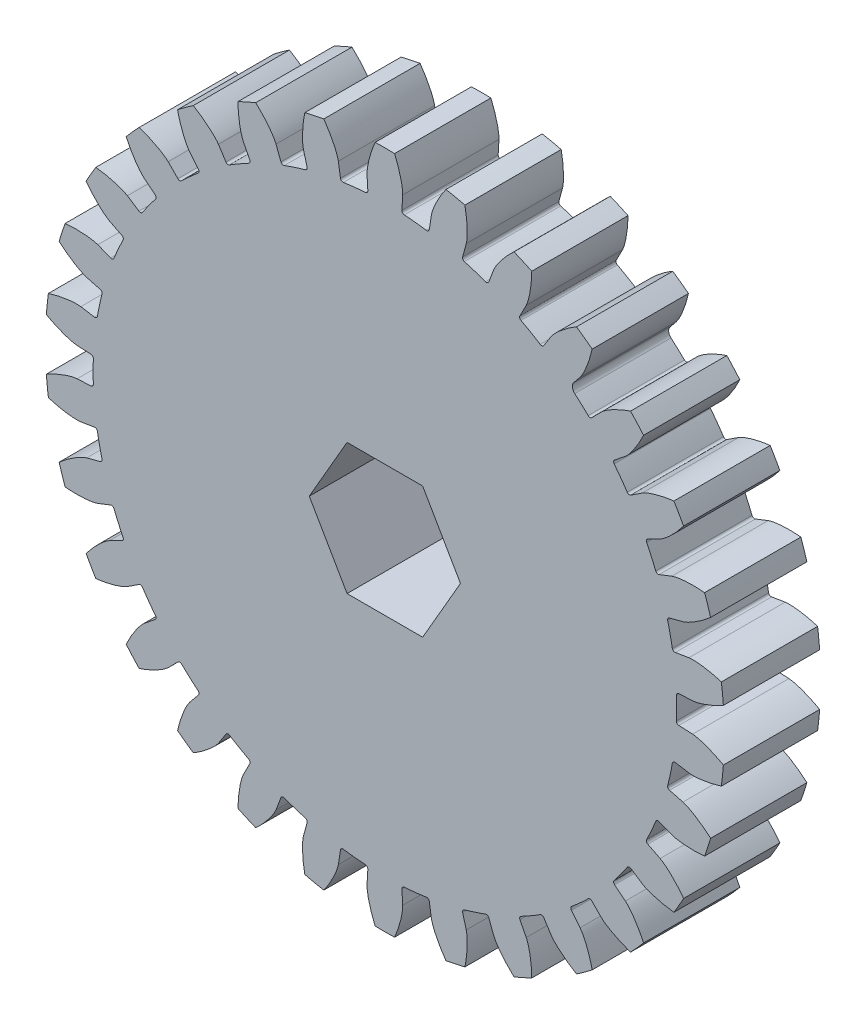
from build123d import *

# Parameters (mm, degrees)
BOSS_EXTRUDE2_DEPTH = 9.525
CUT_EXTRUDE1_DEPTH  = 10.525
CIRPATTERN1_COUNT   = 30
FILLET1_R           = 0.656191159
FILLET2_R           = 0.254
FILLET3_R           = 0.254
SKETCH2_R           = 3.175
CUT_EXTRUDE2_DEPTH  = 2.54
SKETCH3_R           = 3.175
BOSS_EXTRUDE3_DEPTH = 9.525
CUT_EXTRUDE3_DEPTH  = 10.5250001


with BuildPart() as part:
    # Sketch1 → Boss-Extrude2 (new body)
    with BuildSketch(Plane.XY):
        with BuildLine():
            add(Edge.make_bspline(
                [(30.45124914, 1.426618654), (30.456061858, 1.426891336), (30.469553395, 1.427802063), (30.49503231, 1.430100136), (30.536568161, 1.43466882), (30.589432197, 1.441694058), (30.657689376, 1.452157439), (30.738003128, 1.466263239), (30.826163492, 1.483630667), (30.921963231, 1.504540364), (31.017431444, 1.527183187), (31.112562952, 1.551430634), (31.207232939, 1.57708267), (31.321790383, 1.609926897), (31.458987695, 1.65177289), (31.619093687, 1.704276291), (31.800365602, 1.768064008), (31.984767175, 1.837616216), (32.165929064, 1.909788843), (32.348624865, 1.987009098), (32.525148346, 2.06476986), (32.708139717, 2.149952723), (32.876864677, 2.230823601), (33.065486053, 2.326321095), (33.217584866, 2.404815536), (33.374352642, 2.489986603), (33.450600871, 2.532043297), (33.489546581, 2.553791229)],
                knots=[0, 0, 0, 0, 0, 0.005376749, 0.015083688, 0.02853182, 0.04661014, 0.064854849, 0.092110526, 0.119476176, 0.146842496, 0.174208854, 0.201574956, 0.228941013, 0.256307345, 0.307035032, 0.361767352, 0.416499661, 0.471231937, 0.525964282, 0.580696616, 0.635428982, 0.690161387, 0.744893688, 0.799626082, 0.854358407, 0.909090914, 0.909090914, 0.909090914, 0.909090914, 0.909090914], degree=4))
            Line((30.45124914, 1.426618654), (28.832012682, 1.350758615))
            ThreePointArc((28.832012682, 1.350758615), (28.863636364, 0), (28.832012682, -1.350758615))
            Line((28.832012682, -1.350758615), (30.45124914, -1.426618654))
            add(Edge.make_bspline(
                [(30.45124914, -1.426618654), (30.456061858, -1.426891336), (30.469553395, -1.427802063), (30.49503231, -1.430100136), (30.536568161, -1.43466882), (30.589432197, -1.441694058), (30.657689376, -1.452157439), (30.738003128, -1.466263239), (30.826163492, -1.483630667), (30.921963231, -1.504540364), (31.017431444, -1.527183187), (31.112562952, -1.551430634), (31.207232939, -1.57708267), (31.321790383, -1.609926897), (31.458987695, -1.65177289), (31.619093687, -1.704276291), (31.800365602, -1.768064008), (31.984767175, -1.837616216), (32.165929064, -1.909788843), (32.348624865, -1.987009098), (32.525148346, -2.06476986), (32.708139717, -2.149952723), (32.876864677, -2.230823601), (33.065486053, -2.326321095), (33.217584866, -2.404815536), (33.374352642, -2.489986603), (33.450600871, -2.532043297), (33.489546581, -2.553791229)],
                knots=[0, 0, 0, 0, 0, 0.005376749, 0.015083688, 0.02853182, 0.04661014, 0.064854849, 0.092110526, 0.119476176, 0.146842496, 0.174208854, 0.201574956, 0.228941013, 0.256307345, 0.307035032, 0.361767352, 0.416499661, 0.471231937, 0.525964282, 0.580696616, 0.635428982, 0.690161387, 0.744893688, 0.799626082, 0.854358407, 0.909090914, 0.909090914, 0.909090914, 0.909090914, 0.909090914], degree=4))
            ThreePointArc((33.489546581, -2.553791229), (33.562460487, -1.277820739), (33.58677686, 0))
            ThreePointArc((33.58677686, 0), (33.562460487, 1.277820739), (33.489546581, 2.553791229))
        make_face()
        with BuildLine():
            Line((28.832012682, 1.350758615), (30.45124914, 1.426618654))
            add(Edge.make_bspline(
                [(30.45124914, 1.426618654), (30.456061858, 1.426891336), (30.469553395, 1.427802063), (30.49503231, 1.430100136), (30.536568161, 1.43466882), (30.589432197, 1.441694058), (30.657689376, 1.452157439), (30.738003128, 1.466263239), (30.826163492, 1.483630667), (30.921963231, 1.504540364), (31.017431444, 1.527183187), (31.112562952, 1.551430634), (31.207232939, 1.57708267), (31.321790383, 1.609926897), (31.458987695, 1.65177289), (31.619093687, 1.704276291), (31.800365602, 1.768064008), (31.984767175, 1.837616216), (32.165929064, 1.909788843), (32.348624865, 1.987009098), (32.525148346, 2.06476986), (32.708139717, 2.149952723), (32.876864677, 2.230823601), (33.065486053, 2.326321095), (33.217584866, 2.404815536), (33.374352642, 2.489986603), (33.450600871, 2.532043297), (33.489546581, 2.553791229)],
                knots=[0, 0, 0, 0, 0, 0.005376749, 0.015083688, 0.02853182, 0.04661014, 0.064854849, 0.092110526, 0.119476176, 0.146842496, 0.174208854, 0.201574956, 0.228941013, 0.256307345, 0.307035032, 0.361767352, 0.416499661, 0.471231937, 0.525964282, 0.580696616, 0.635428982, 0.690161387, 0.744893688, 0.799626082, 0.854358407, 0.909090914, 0.909090914, 0.909090914, 0.909090914, 0.909090914], degree=4))
            ThreePointArc((33.489546581, 2.553791229), (-33.58677686, 0), (33.489546581, -2.553791229))
            add(Edge.make_bspline(
                [(30.45124914, -1.426618654), (30.456061858, -1.426891336), (30.469553395, -1.427802063), (30.49503231, -1.430100136), (30.536568161, -1.43466882), (30.589432197, -1.441694058), (30.657689376, -1.452157439), (30.738003128, -1.466263239), (30.826163492, -1.483630667), (30.921963231, -1.504540364), (31.017431444, -1.527183187), (31.112562952, -1.551430634), (31.207232939, -1.57708267), (31.321790383, -1.609926897), (31.458987695, -1.65177289), (31.619093687, -1.704276291), (31.800365602, -1.768064008), (31.984767175, -1.837616216), (32.165929064, -1.909788843), (32.348624865, -1.987009098), (32.525148346, -2.06476986), (32.708139717, -2.149952723), (32.876864677, -2.230823601), (33.065486053, -2.326321095), (33.217584866, -2.404815536), (33.374352642, -2.489986603), (33.450600871, -2.532043297), (33.489546581, -2.553791229)],
                knots=[0, 0, 0, 0, 0, 0.005376749, 0.015083688, 0.02853182, 0.04661014, 0.064854849, 0.092110526, 0.119476176, 0.146842496, 0.174208854, 0.201574956, 0.228941013, 0.256307345, 0.307035032, 0.361767352, 0.416499661, 0.471231937, 0.525964282, 0.580696616, 0.635428982, 0.690161387, 0.744893688, 0.799626082, 0.854358407, 0.909090914, 0.909090914, 0.909090914, 0.909090914, 0.909090914], degree=4))
            Line((30.45124914, -1.426618654), (28.832012682, -1.350758615))
            ThreePointArc((28.832012682, -1.350758615), (28.863636364, 0), (28.832012682, 1.350758615))
        make_face()
        with BuildLine():
            add(Edge.make_bspline(
                [(30.45124914, 1.426618654), (30.456061858, 1.426891336), (30.469553395, 1.427802063), (30.49503231, 1.430100136), (30.536568161, 1.43466882), (30.589432197, 1.441694058), (30.657689376, 1.452157439), (30.738003128, 1.466263239), (30.826163492, 1.483630667), (30.921963231, 1.504540364), (31.017431444, 1.527183187), (31.112562952, 1.551430634), (31.207232939, 1.57708267), (31.321790383, 1.609926897), (31.458987695, 1.65177289), (31.619093687, 1.704276291), (31.800365602, 1.768064008), (31.984767175, 1.837616216), (32.165929064, 1.909788843), (32.348624865, 1.987009098), (32.525148346, 2.06476986), (32.708139717, 2.149952723), (32.876864677, 2.230823601), (33.065486053, 2.326321095), (33.217584866, 2.404815536), (33.374352642, 2.489986603), (33.450600871, 2.532043297), (33.489546581, 2.553791229)],
                knots=[0, 0, 0, 0, 0, 0.005376749, 0.015083688, 0.02853182, 0.04661014, 0.064854849, 0.092110526, 0.119476176, 0.146842496, 0.174208854, 0.201574956, 0.228941013, 0.256307345, 0.307035032, 0.361767352, 0.416499661, 0.471231937, 0.525964282, 0.580696616, 0.635428982, 0.690161387, 0.744893688, 0.799626082, 0.854358407, 0.909090914, 0.909090914, 0.909090914, 0.909090914, 0.909090914], degree=4))
            Line((30.45124914, 1.426618654), (28.832012682, 1.350758615))
            ThreePointArc((28.832012682, 1.350758615), (28.863636364, 0), (28.832012682, -1.350758615))
            Line((28.832012682, -1.350758615), (30.45124914, -1.426618654))
            add(Edge.make_bspline(
                [(30.45124914, -1.426618654), (30.456061858, -1.426891336), (30.469553395, -1.427802063), (30.49503231, -1.430100136), (30.536568161, -1.43466882), (30.589432197, -1.441694058), (30.657689376, -1.452157439), (30.738003128, -1.466263239), (30.826163492, -1.483630667), (30.921963231, -1.504540364), (31.017431444, -1.527183187), (31.112562952, -1.551430634), (31.207232939, -1.57708267), (31.321790383, -1.609926897), (31.458987695, -1.65177289), (31.619093687, -1.704276291), (31.800365602, -1.768064008), (31.984767175, -1.837616216), (32.165929064, -1.909788843), (32.348624865, -1.987009098), (32.525148346, -2.06476986), (32.708139717, -2.149952723), (32.876864677, -2.230823601), (33.065486053, -2.326321095), (33.217584866, -2.404815536), (33.374352642, -2.489986603), (33.450600871, -2.532043297), (33.489546581, -2.553791229)],
                knots=[0, 0, 0, 0, 0, 0.005376749, 0.015083688, 0.02853182, 0.04661014, 0.064854849, 0.092110526, 0.119476176, 0.146842496, 0.174208854, 0.201574956, 0.228941013, 0.256307345, 0.307035032, 0.361767352, 0.416499661, 0.471231937, 0.525964282, 0.580696616, 0.635428982, 0.690161387, 0.744893688, 0.799626082, 0.854358407, 0.909090914, 0.909090914, 0.909090914, 0.909090914, 0.909090914], degree=4))
            ThreePointArc((33.489546581, -2.553791229), (33.562460487, -1.277820739), (33.58677686, 0))
            ThreePointArc((33.58677686, 0), (33.562460487, 1.277820739), (33.489546581, 2.553791229))
        make_face()
        with BuildLine():
            Line((28.832012682, 1.350758615), (30.45124914, 1.426618654))
            add(Edge.make_bspline(
                [(30.45124914, 1.426618654), (30.456061858, 1.426891336), (30.469553395, 1.427802063), (30.49503231, 1.430100136), (30.536568161, 1.43466882), (30.589432197, 1.441694058), (30.657689376, 1.452157439), (30.738003128, 1.466263239), (30.826163492, 1.483630667), (30.921963231, 1.504540364), (31.017431444, 1.527183187), (31.112562952, 1.551430634), (31.207232939, 1.57708267), (31.321790383, 1.609926897), (31.458987695, 1.65177289), (31.619093687, 1.704276291), (31.800365602, 1.768064008), (31.984767175, 1.837616216), (32.165929064, 1.909788843), (32.348624865, 1.987009098), (32.525148346, 2.06476986), (32.708139717, 2.149952723), (32.876864677, 2.230823601), (33.065486053, 2.326321095), (33.217584866, 2.404815536), (33.374352642, 2.489986603), (33.450600871, 2.532043297), (33.489546581, 2.553791229)],
                knots=[0, 0, 0, 0, 0, 0.005376749, 0.015083688, 0.02853182, 0.04661014, 0.064854849, 0.092110526, 0.119476176, 0.146842496, 0.174208854, 0.201574956, 0.228941013, 0.256307345, 0.307035032, 0.361767352, 0.416499661, 0.471231937, 0.525964282, 0.580696616, 0.635428982, 0.690161387, 0.744893688, 0.799626082, 0.854358407, 0.909090914, 0.909090914, 0.909090914, 0.909090914, 0.909090914], degree=4))
            ThreePointArc((33.489546581, 2.553791229), (-33.58677686, 0), (33.489546581, -2.553791229))
            add(Edge.make_bspline(
                [(30.45124914, -1.426618654), (30.456061858, -1.426891336), (30.469553395, -1.427802063), (30.49503231, -1.430100136), (30.536568161, -1.43466882), (30.589432197, -1.441694058), (30.657689376, -1.452157439), (30.738003128, -1.466263239), (30.826163492, -1.483630667), (30.921963231, -1.504540364), (31.017431444, -1.527183187), (31.112562952, -1.551430634), (31.207232939, -1.57708267), (31.321790383, -1.609926897), (31.458987695, -1.65177289), (31.619093687, -1.704276291), (31.800365602, -1.768064008), (31.984767175, -1.837616216), (32.165929064, -1.909788843), (32.348624865, -1.987009098), (32.525148346, -2.06476986), (32.708139717, -2.149952723), (32.876864677, -2.230823601), (33.065486053, -2.326321095), (33.217584866, -2.404815536), (33.374352642, -2.489986603), (33.450600871, -2.532043297), (33.489546581, -2.553791229)],
                knots=[0, 0, 0, 0, 0, 0.005376749, 0.015083688, 0.02853182, 0.04661014, 0.064854849, 0.092110526, 0.119476176, 0.146842496, 0.174208854, 0.201574956, 0.228941013, 0.256307345, 0.307035032, 0.361767352, 0.416499661, 0.471231937, 0.525964282, 0.580696616, 0.635428982, 0.690161387, 0.744893688, 0.799626082, 0.854358407, 0.909090914, 0.909090914, 0.909090914, 0.909090914, 0.909090914], degree=4))
            Line((30.45124914, -1.426618654), (28.832012682, -1.350758615))
            ThreePointArc((28.832012682, -1.350758615), (28.863636364, 0), (28.832012682, 1.350758615))
        make_face()
    extrude(amount=BOSS_EXTRUDE2_DEPTH)

    # Sketch1_5 → Cut-Extrude1 (cut, through all)
    with BuildSketch(Plane.XY):
        with BuildLine():
            add(Edge.make_bspline(
                [(30.45124914, 1.426618654), (30.456061858, 1.426891336), (30.469553395, 1.427802063), (30.49503231, 1.430100136), (30.536568161, 1.43466882), (30.589432197, 1.441694058), (30.657689376, 1.452157439), (30.738003128, 1.466263239), (30.826163492, 1.483630667), (30.921963231, 1.504540364), (31.017431444, 1.527183187), (31.112562952, 1.551430634), (31.207232939, 1.57708267), (31.321790383, 1.609926897), (31.458987695, 1.65177289), (31.619093687, 1.704276291), (31.800365602, 1.768064008), (31.984767175, 1.837616216), (32.165929064, 1.909788843), (32.348624865, 1.987009098), (32.525148346, 2.06476986), (32.708139717, 2.149952723), (32.876864677, 2.230823601), (33.065486053, 2.326321095), (33.217584866, 2.404815536), (33.374352642, 2.489986603), (33.450600871, 2.532043297), (33.489546581, 2.553791229)],
                knots=[0, 0, 0, 0, 0, 0.005376749, 0.015083688, 0.02853182, 0.04661014, 0.064854849, 0.092110526, 0.119476176, 0.146842496, 0.174208854, 0.201574956, 0.228941013, 0.256307345, 0.307035032, 0.361767352, 0.416499661, 0.471231937, 0.525964282, 0.580696616, 0.635428982, 0.690161387, 0.744893688, 0.799626082, 0.854358407, 0.909090914, 0.909090914, 0.909090914, 0.909090914, 0.909090914], degree=4))
            Line((30.45124914, 1.426618654), (28.832012682, 1.350758615))
            ThreePointArc((28.832012682, 1.350758615), (28.863636364, 0), (28.832012682, -1.350758615))
            Line((28.832012682, -1.350758615), (30.45124914, -1.426618654))
            add(Edge.make_bspline(
                [(30.45124914, -1.426618654), (30.456061858, -1.426891336), (30.469553395, -1.427802063), (30.49503231, -1.430100136), (30.536568161, -1.43466882), (30.589432197, -1.441694058), (30.657689376, -1.452157439), (30.738003128, -1.466263239), (30.826163492, -1.483630667), (30.921963231, -1.504540364), (31.017431444, -1.527183187), (31.112562952, -1.551430634), (31.207232939, -1.57708267), (31.321790383, -1.609926897), (31.458987695, -1.65177289), (31.619093687, -1.704276291), (31.800365602, -1.768064008), (31.984767175, -1.837616216), (32.165929064, -1.909788843), (32.348624865, -1.987009098), (32.525148346, -2.06476986), (32.708139717, -2.149952723), (32.876864677, -2.230823601), (33.065486053, -2.326321095), (33.217584866, -2.404815536), (33.374352642, -2.489986603), (33.450600871, -2.532043297), (33.489546581, -2.553791229)],
                knots=[0, 0, 0, 0, 0, 0.005376749, 0.015083688, 0.02853182, 0.04661014, 0.064854849, 0.092110526, 0.119476176, 0.146842496, 0.174208854, 0.201574956, 0.228941013, 0.256307345, 0.307035032, 0.361767352, 0.416499661, 0.471231937, 0.525964282, 0.580696616, 0.635428982, 0.690161387, 0.744893688, 0.799626082, 0.854358407, 0.909090914, 0.909090914, 0.909090914, 0.909090914, 0.909090914], degree=4))
            ThreePointArc((33.489546581, -2.553791229), (33.562460487, -1.277820739), (33.58677686, 0))
            ThreePointArc((33.58677686, 0), (33.562460487, 1.277820739), (33.489546581, 2.553791229))
        make_face()
    cut_extrude1 = extrude(amount=CUT_EXTRUDE1_DEPTH, mode=Mode.SUBTRACT)

    # CirPattern1: Cut-Extrude1 ×30 about axis
    cirpattern1_axis = Axis((0, 0, 9.525), (0, 0, -1))
    for i in range(1, CIRPATTERN1_COUNT):
        add(cut_extrude1.rotate(cirpattern1_axis, i * 360 / CIRPATTERN1_COUNT), mode=Mode.SUBTRACT)

    # Fillet1
    fillet1_edges = [part.edges().sort_by_distance(p)[0] for p in [
        (18.288572853, 22.330194964, 4.7625),
    ]]
    fillet(fillet1_edges, radius=FILLET1_R)

    # Fillet2
    fillet2_edges = [part.edges().sort_by_distance(p)[0] for p in [
        (15.585797616, 24.293876117, 4.7625),
        (13.246215066, 25.644634732, 4.7625),
        (10.194229684, 27.003466172, 4.7625),
        (7.624934118, 27.838280907, 4.7625),
        (28.832012682, -1.350758615, 4.7625),
        (28.832012682, 1.350758615, 4.7625),
        (4.357124997, 28.532875178, 4.7625),
        (1.67040696, 28.815260622, 4.7625),
        (-1.67040696, 28.815260622, 4.7625),
        (-4.357124997, 28.532875178, 4.7625),
        (-7.624934118, 27.838280907, 4.7625),
        (-10.194229684, 27.003466172, 4.7625),
        (-13.246215066, 25.644634732, 4.7625),
        (-15.585797616, 24.293876117, 4.7625),
        (-18.288572853, 22.330194964, 4.7625),
        (-20.296191404, 20.522527101, 4.7625),
        (-22.531632248, 18.039818523, 4.7625),
        (-24.119544235, 15.854245173, 4.7625),
        (-25.789951196, 12.961015449, 4.7625),
        (-26.888757245, 10.493056654, 4.7625),
        (-27.921125522, 7.315753805, 4.7625),
        (-28.482802537, 4.673271208, 4.7625),
        (-28.832012682, 1.350758615, 4.7625),
        (-28.832012682, -1.350758615, 4.7625),
        (-28.482802537, -4.673271208, 4.7625),
        (-27.921125522, -7.315753805, 4.7625),
        (-26.888757245, -10.493056654, 4.7625),
        (-25.789951196, -12.961015449, 4.7625),
        (28.482802537, 4.673271208, 4.7625),
        (27.921125522, 7.315753805, 4.7625),
        (-24.119544235, -15.854245173, 4.7625),
        (-22.531632248, -18.039818523, 4.7625),
        (-20.296191404, -20.522527101, 4.7625),
        (-18.288572853, -22.330194964, 4.7625),
        (-15.585797616, -24.293876117, 4.7625),
        (-13.246215066, -25.644634732, 4.7625),
        (-10.194229684, -27.003466172, 4.7625),
        (-7.624934118, -27.838280907, 4.7625),
        (-4.357124997, -28.532875178, 4.7625),
        (-1.67040696, -28.815260622, 4.7625),
        (1.67040696, -28.815260622, 4.7625),
        (4.357124997, -28.532875178, 4.7625),
        (26.888757245, 10.493056654, 4.7625),
        (25.789951196, 12.961015449, 4.7625),
        (24.119544235, 15.854245173, 4.7625),
        (22.531632248, 18.039818523, 4.7625),
        (20.296191404, 20.522527101, 4.7625),
    ]]
    fillet(fillet2_edges, radius=FILLET2_R)

    # Fillet3
    fillet3_edges = [part.edges().sort_by_distance(p)[0] for p in [
        (7.624934118, -27.838280907, 4.7625),
        (10.194229684, -27.003466172, 4.7625),
        (13.246215066, -25.644634732, 4.7625),
        (15.585797616, -24.293876117, 4.7625),
        (18.288572853, -22.330194964, 4.7625),
        (20.296191404, -20.522527101, 4.7625),
        (22.531632248, -18.039818523, 4.7625),
        (24.119544235, -15.854245173, 4.7625),
        (25.789951196, -12.961015449, 4.7625),
        (26.888757245, -10.493056654, 4.7625),
        (27.921125522, -7.315753805, 4.7625),
        (28.482802537, -4.673271208, 4.7625),
    ]]
    fillet(fillet3_edges, radius=FILLET3_R)

    # Sketch2 → Cut-Extrude2 (cut)
    with BuildSketch(Plane(origin=(0, 0, 0), x_dir=(-1, 0, 0), z_dir=(0, 0, -1))):
        Circle(SKETCH2_R)
    extrude(amount=-CUT_EXTRUDE2_DEPTH, mode=Mode.SUBTRACT)

    # Sketch3 → Boss-Extrude3 (add)
    with BuildSketch(Plane(origin=(0, 0, 0), x_dir=(-1, 0, 0), z_dir=(0, 0, -1))):
        Circle(SKETCH3_R)
    extrude(amount=-BOSS_EXTRUDE3_DEPTH)

    # Sketch4 → Cut-Extrude3 (cut, through all)
    with BuildSketch(Plane(origin=(0, 0, 0), x_dir=(-1, 0, 0), z_dir=(0, 0, -1))):
        Polygon((3.739497694, 6.477), (-3.739497694, 6.477), (-7.478995387, 0), (-3.739497694, -6.477), (3.739497694, -6.477), (7.478995387, 0), align=None)
    extrude(amount=-CUT_EXTRUDE3_DEPTH, mode=Mode.SUBTRACT)


solid = part.part
